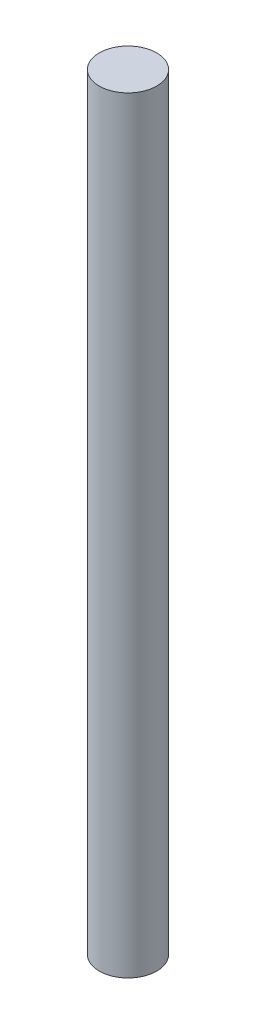
from build123d import *

# Parameters (mm, degrees)
SKETCH1_R           = 1.5
BOSS_EXTRUDE1_DEPTH = 40


with BuildPart() as part:
    # Sketch1 → Boss-Extrude1 (new body)
    with BuildSketch(Plane(origin=(0, 0, 0), x_dir=(1, 0, 0), z_dir=(0, 1, 0))):
        Circle(SKETCH1_R)
    extrude(amount=BOSS_EXTRUDE1_DEPTH)


solid = part.part
